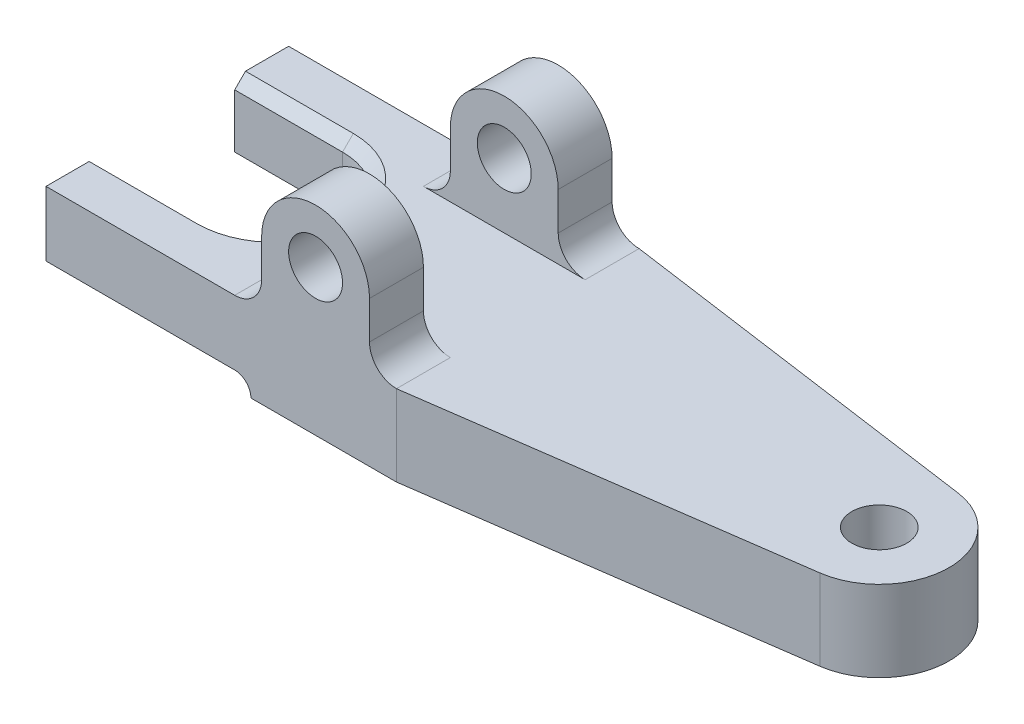
from build123d import *

# Parameters (mm, degrees)
DODANIE_WYCI_GNI_CIE1_DEPTH = 15
WYTNIJ_WYCI_GNI_CIE1_DEPTH  = 46
SZKIC3_R                    = 5
DODANIE_WYCI_GNI_CIE2_DEPTH = 10
ZAOKR_GLENIE1_R             = 5
ZAOKR_GLENIE1_OF_LUSTRO1_R  = 5
SFAZOWANIE1_SIZE            = 2
OTW_R_GWINTOWANY_M121_D     = 10.2


with BuildPart() as part:
    # Szkic1 → Dodanie-wyciągnięcie1 (new body)
    with BuildSketch(Plane(origin=(0, 0, 0), x_dir=(1, 0, 0), z_dir=(0, 1, 0))):
        with BuildLine():
            Line((-20, 12.5), (-20, 22.5))
            Line((-20, 22.5), (45, 22.5))
            Line((45, 22.5), (113.85281653, 12.823367693))
            ThreePointArc((113.85281653, 12.823367693), (125, 0), (113.85281653, -12.823367693))
            Line((113.85281653, -12.823367693), (45, -22.5))
            Line((45, -22.5), (-20, -22.5))
            Line((-20, -22.5), (-20, -12.5))
            Line((-20, -12.5), (0, -12.5))
            ThreePointArc((0, -12.5), (12.5, 0), (0, 12.5))
            Line((0, 12.5), (-20, 12.5))
        make_face()
    extrude(amount=DODANIE_WYCI_GNI_CIE1_DEPTH)

    # Szkic2 → Wytnij-wyciągnięcie1 (cut, through all)
    with BuildSketch(Plane.XY.offset(22.5)):
        with BuildLine():
            Line((-20, 3), (15, 3))
            ThreePointArc((15, 3), (17.121320344, 2.121320344), (18, 0))
            Line((18, 0), (-20, 0))
            Line((-20, 0), (-20, 3))
        make_face()
    extrude(amount=-WYTNIJ_WYCI_GNI_CIE1_DEPTH, mode=Mode.SUBTRACT)

    # Szkic3 → Dodanie-wyciągnięcie2 (add)
    with BuildSketch(Plane.XY.offset(22.5)):
        with BuildLine():
            Line((20, 15), (20, 27))
            ThreePointArc((20, 27), (30, 37), (40, 27))
            Line((40, 27), (40, 15))
            Line((40, 15), (20, 15))
        make_face()
        with Locations((30, 27)):
            Circle(SZKIC3_R, mode=Mode.SUBTRACT)
    dodanie_wyci_gni_cie2 = extrude(amount=-DODANIE_WYCI_GNI_CIE2_DEPTH)

    # Zaokrąglenie1
    zaokr_glenie1_edges = [part.edges().sort_by_distance(p)[0] for p in [
        (40, 15, 17.5),
        (20, 15, 17.5),
    ]]
    fillet(zaokr_glenie1_edges, radius=ZAOKR_GLENIE1_R)

    # Lustro1: Dodanie-wyciągnięcie2 across plane
    add(dodanie_wyci_gni_cie2.mirror(Plane.XY))

    # Zaokrąglenie1 of Lustro1
    zaokr_glenie1_of_lustro1_edges = [part.edges().sort_by_distance(p)[0] for p in [
        (40, 15, -17.5),
        (20, 15, -17.5),
    ]]
    fillet(zaokr_glenie1_of_lustro1_edges, radius=ZAOKR_GLENIE1_OF_LUSTRO1_R)

    # Sfazowanie1
    sfazowanie1_edges = [part.edges().sort_by_distance(p)[0] for p in [
        (-10, 15, 12.5),
        (-10, 15, -12.5),
        (12.5, 15, 0),
    ]]
    chamfer(sfazowanie1_edges, length=SFAZOWANIE1_SIZE)

    # Otwór gwintowany M121 (through all)
    with Locations(Plane(origin=(0, 15, 0), x_dir=(1, 0, 0), z_dir=(0, 1, 0))):
        with Locations((112.050609731, 0)):
            Hole(OTW_R_GWINTOWANY_M121_D / 2)


solid = part.part
